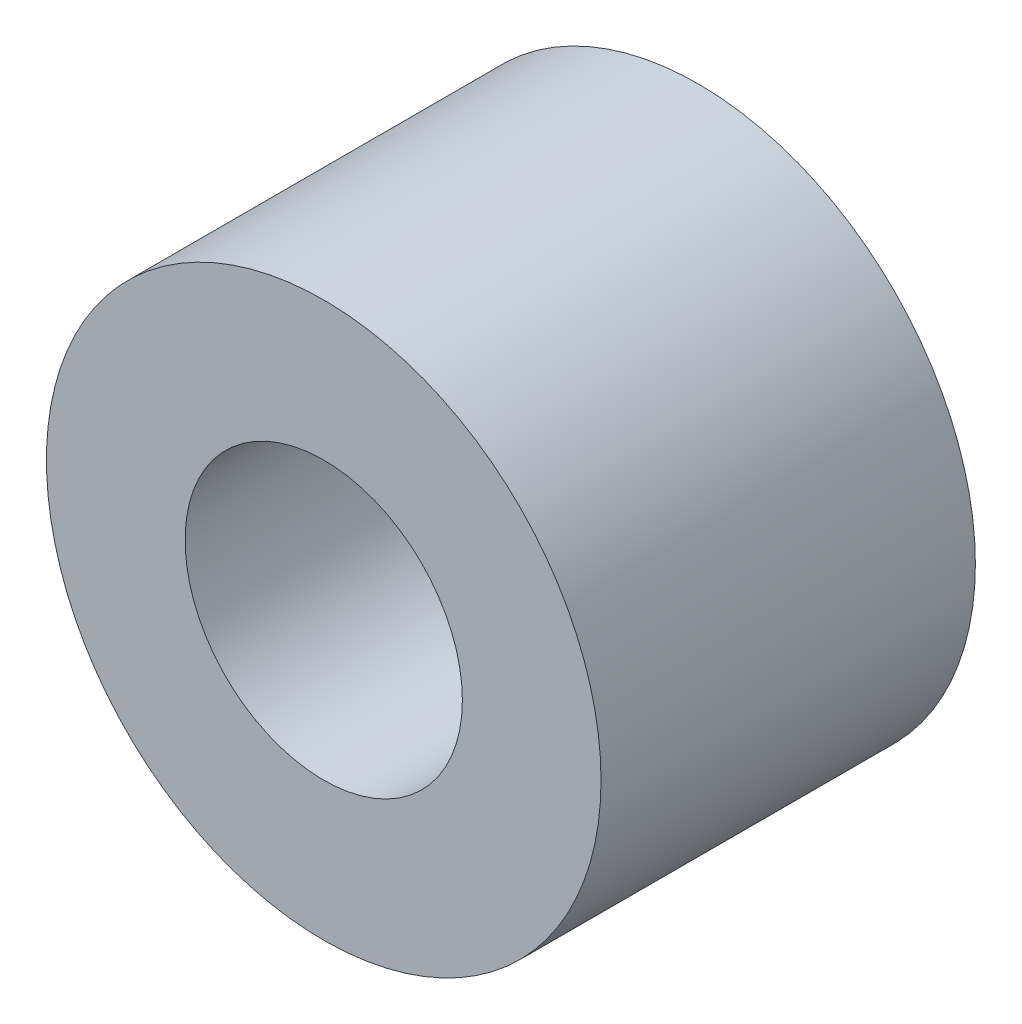
from build123d import *

# Parameters (mm, degrees)
CROQUIS1_R              = 2
CROQUIS1_R_2            = 1
SALIENTE_EXTRUIR1_DEPTH = 2.7


with BuildPart() as part:
    # Croquis1 → Saliente-Extruir1 (new body)
    with BuildSketch(Plane.XY):
        Circle(CROQUIS1_R)
        Circle(CROQUIS1_R_2, mode=Mode.SUBTRACT)
    extrude(amount=SALIENTE_EXTRUIR1_DEPTH)


solid = part.part
